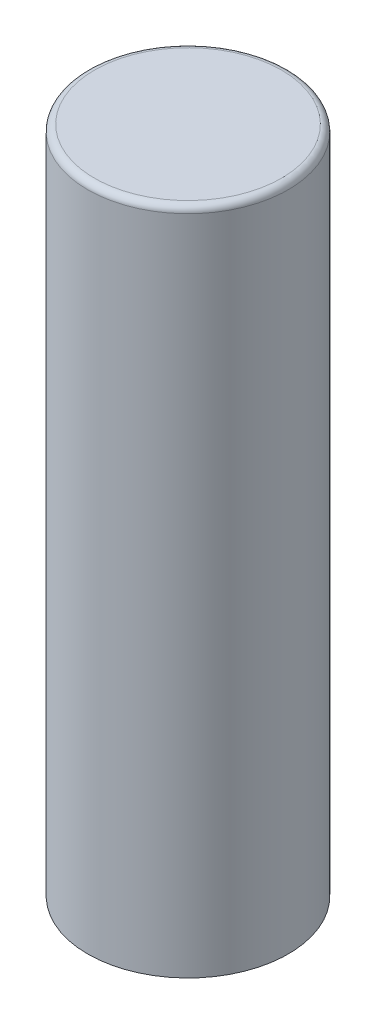
from build123d import *


with BuildPart() as part:
    # Croquis1 → Revolución1 (revolve)
    with BuildSketch(Plane.XY):
        with BuildLine():
            Line((0, 350), (-49, 350))
            ThreePointArc((-49, 350), (-51.474873734, 348.974873734), (-52.5, 346.5))
            Line((-52.5, 346.5), (-52.5, 0))
            Line((-52.5, 0), (-45.5, 0))
            Line((-45.5, 0), (-45.5, 343))
            Line((-45.5, 343), (0, 343))
            Line((0, 343), (0, 350))
        make_face()
    revolve(axis=Axis((0, 0, 0), (0, 1, 0)))


solid = part.part
